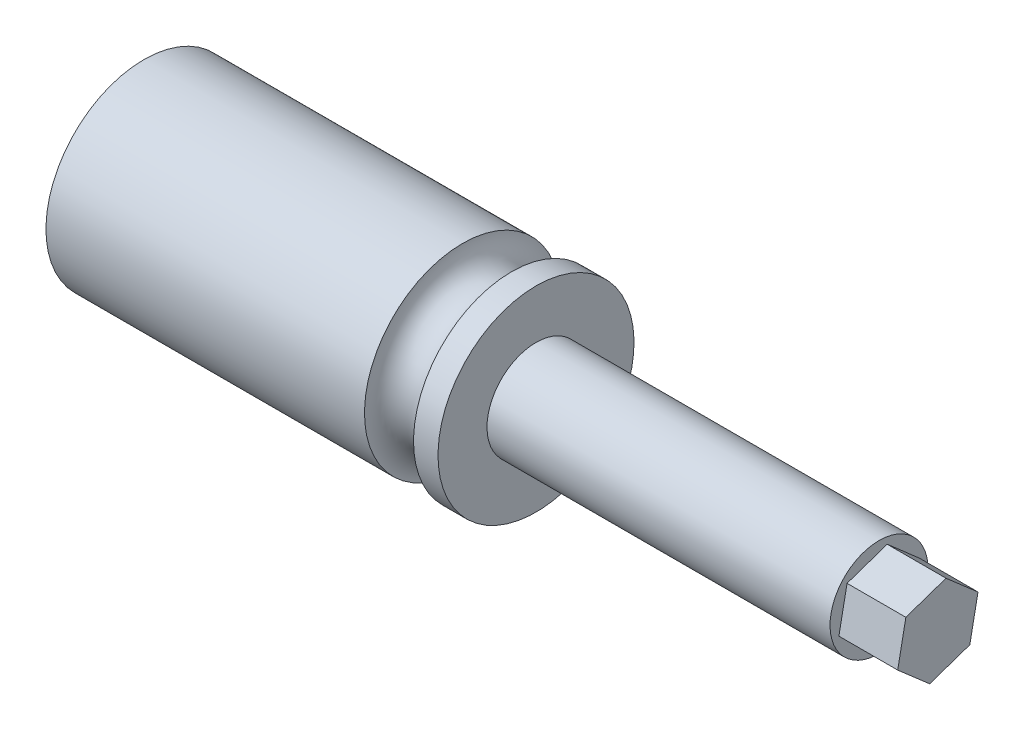
from build123d import *

# Parameters (mm, degrees)
BOSS_EXTRUDE1_DEPTH = 15.24


with BuildPart() as part:
    # Sketch1 → Revolve1 (revolve)
    with BuildSketch(Plane.XY):
        with BuildLine():
            Line((0, 0), (-101.6, 0))
            Line((-101.6, 0), (-101.6, 25.4))
            Line((-101.6, 25.4), (-19.05, 25.4))
            ThreePointArc((-19.05, 25.4), (-12.7, 19.05), (-6.35, 25.4))
            Line((-6.35, 25.4), (0, 25.4))
            Line((0, 25.4), (0, 12.7))
            Line((0, 12.7), (88.9, 12.7))
            Line((88.9, 12.7), (88.9, 0))
            Line((88.9, 0), (0, 0))
        make_face()
    revolve(axis=Axis((0, 0, 0), (-1, 0, 0)))

    # Sketch2 → Boss-Extrude1 (add)
    with BuildSketch(Plane(origin=(88.9, 0, 0), x_dir=(0, 0, -1), z_dir=(1, 0, 0))):
        Polygon((8.288184077, -7.230041819), (10.405491924, 3.562757053), (2.117307847, 10.792798872), (-8.288184077, 7.230041819), (-10.405491924, -3.562757053), (-2.117307847, -10.792798872), align=None)
    extrude(amount=BOSS_EXTRUDE1_DEPTH)


solid = part.part
